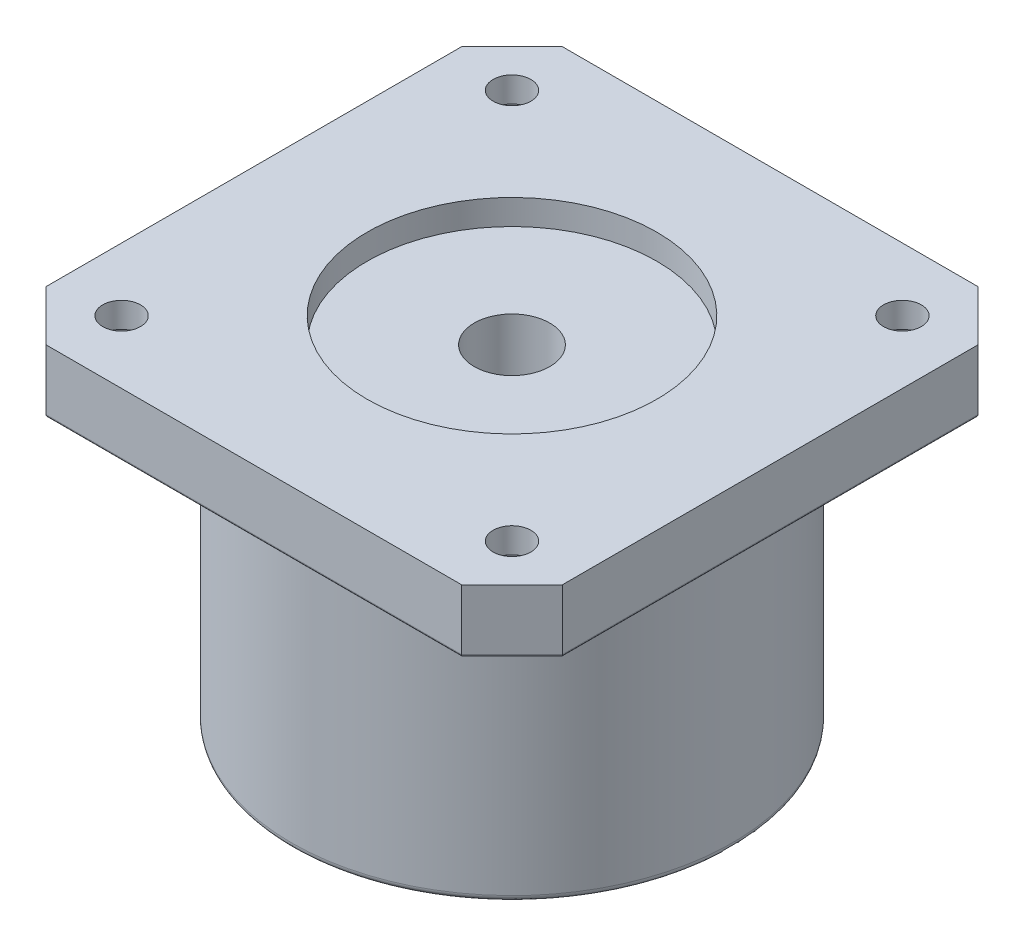
from build123d import *

# Parameters (mm, degrees)
SKETCH1_W           = 41
SKETCH1_H           = 41
BOSS_EXTRUDE1_DEPTH = 5
CUT_EXTRUDE2_DEPTH  = 5
SKETCH4_R           = 11.5
CUT_EXTRUDE3_DEPTH  = 2
SKETCH6_R           = 17.5
BOSS_EXTRUDE2_DEPTH = 23
FILLET1_R           = 0.2
FILLET2_R           = 0.5
SKETCH13_R          = 11
BOSS_EXTRUDE3_DEPTH = 2
SKETCH5_R           = 3
CUT_EXTRUDE9_DEPTH  = 31
SKETCH14_R          = 2.5
CUT_EXTRUDE10_DEPTH = 5
SKETCH15_R          = 1.5
CUT_EXTRUDE11_DEPTH = 5
SKETCH16_R          = 2.5
CUT_EXTRUDE12_DEPTH = 3
SKETCH17_R          = 1.5
CUT_EXTRUDE13_DEPTH = 3
SKETCH18_R          = 1.5
CUT_EXTRUDE14_DEPTH = 5


with BuildPart() as part:
    # Sketch1 → Boss-Extrude1 (new body)
    with BuildSketch(Plane(origin=(0, 0, 0), x_dir=(1, 0, 0), z_dir=(0, 1, 0))):
        with Locations((20.5, 20.5)):
            Rectangle(SKETCH1_W, SKETCH1_H)
    extrude(amount=BOSS_EXTRUDE1_DEPTH)

    # Sketch2 → Cut-Extrude2 (cut)
    with BuildSketch(Plane(origin=(0, 5, 0), x_dir=(1, 0, 0), z_dir=(0, 1, 0))):
        Polygon((0, 4), (0, 0), (4, 0), align=None)
        Polygon((0, 41), (0, 37), (4, 41), align=None)
        Polygon((41, 41), (37, 41), (41, 37), align=None)
        Polygon((41, 4), (37, 0), (41, 0), align=None)
    extrude(amount=-CUT_EXTRUDE2_DEPTH, mode=Mode.SUBTRACT)

    # Sketch4 → Cut-Extrude3 (cut)
    with BuildSketch(Plane(origin=(0, 5, 0), x_dir=(1, 0, 0), z_dir=(0, 1, 0))):
        with Locations((20.5, 20.5)):
            Circle(SKETCH4_R)
    extrude(amount=-CUT_EXTRUDE3_DEPTH, mode=Mode.SUBTRACT)

    # Sketch6 → Boss-Extrude2 (add)
    with BuildSketch(Plane.XZ):
        with Locations((20.5, -20.5)):
            Circle(SKETCH6_R)
    extrude(amount=BOSS_EXTRUDE2_DEPTH)

    # Fillet1
    fillet1_edges = [part.edges().sort_by_distance(p)[0] for p in [
        (20.5, 0, 0),
        (2, 0, -2),
        (0, 0, -20.5),
        (2, 0, -39),
        (20.5, 0, -41),
        (39, 0, -39),
        (41, 0, -20.5),
        (39, 0, -2),
    ]]
    fillet(fillet1_edges, radius=FILLET1_R)

    # Fillet2
    fillet2_edges = [part.edges().sort_by_distance(p)[0] for p in [
        (3, -23, -20.5),
    ]]
    fillet(fillet2_edges, radius=FILLET2_R)

    # Sketch13 → Boss-Extrude3 (add)
    with BuildSketch(Plane(origin=(0, -23, 0), x_dir=(-1, 0, 0), z_dir=(0, -1, 0))):
        with Locations((-20.5, 20.5)):
            Circle(SKETCH13_R)
    extrude(amount=BOSS_EXTRUDE3_DEPTH)

    # Sketch5 → Cut-Extrude9 (cut, through all)
    with BuildSketch(Plane(origin=(0, 5, 0), x_dir=(1, 0, 0), z_dir=(0, 1, 0))):
        with Locations((20.5, 20.5)):
            Circle(SKETCH5_R)
    extrude(amount=-CUT_EXTRUDE9_DEPTH, mode=Mode.SUBTRACT)

    # Sketch14 → Cut-Extrude10 (cut)
    with BuildSketch(Plane(origin=(0, -23, 0), x_dir=(-1, 0, 0), z_dir=(0, -1, 0))):
        with Locations((-20.5, 6.5)):
            Circle(SKETCH14_R)
        with Locations((-34.5, 20.5)):
            Circle(SKETCH14_R)
        with Locations((-20.5, 34.5)):
            Circle(SKETCH14_R)
        with Locations((-6.5, 20.5)):
            Circle(SKETCH14_R)
    extrude(amount=-CUT_EXTRUDE10_DEPTH, mode=Mode.SUBTRACT)

    # Sketch15 → Cut-Extrude11 (cut)
    with BuildSketch(Plane(origin=(0, -23, 0), x_dir=(-1, 0, 0), z_dir=(0, -1, 0))):
        with Locations((-6.357864376, 20.5)):
            Circle(SKETCH15_R)
        with Locations((-30.5, 10.5)):
            Circle(SKETCH15_R)
        with Locations((-20.5, 6.357864376)):
            Circle(SKETCH15_R)
        with Locations((-30.5, 30.5)):
            Circle(SKETCH15_R)
        with Locations((-34.642135624, 20.5)):
            Circle(SKETCH15_R)
        with Locations((-10.5, 30.5)):
            Circle(SKETCH15_R)
        with Locations((-20.5, 34.642135624)):
            Circle(SKETCH15_R)
        with Locations((-10.5, 10.5)):
            Circle(SKETCH15_R)
    extrude(amount=-CUT_EXTRUDE11_DEPTH, mode=Mode.SUBTRACT)

    # Sketch16 → Cut-Extrude12 (cut)
    with BuildSketch(Plane(origin=(0, 0, 0), x_dir=(-1, 0, 0), z_dir=(0, -1, 0))):
        with Locations((-5, 5)):
            Circle(SKETCH16_R)
        with Locations((-36, 5)):
            Circle(SKETCH16_R)
        with Locations((-5, 36)):
            Circle(SKETCH16_R)
        with Locations((-36, 36)):
            Circle(SKETCH16_R)
    extrude(amount=-CUT_EXTRUDE12_DEPTH, mode=Mode.SUBTRACT)

    # Sketch17 → Cut-Extrude13 (cut, through all)
    with BuildSketch(Plane(origin=(0, 3, 0), x_dir=(-1, 0, 0), z_dir=(0, -1, 0))):
        with Locations((-5, 5)):
            Circle(SKETCH17_R)
        with Locations((-36, 5)):
            Circle(SKETCH17_R)
        with Locations((-5, 36)):
            Circle(SKETCH17_R)
        with Locations((-36, 36)):
            Circle(SKETCH17_R)
    extrude(amount=-CUT_EXTRUDE13_DEPTH, mode=Mode.SUBTRACT)

    # Sketch18 → Cut-Extrude14 (cut)
    with BuildSketch(Plane.XZ.offset(18)):
        with Locations((6.5, -20.5)):
            Circle(SKETCH18_R)
        with Locations((34.5, -20.5)):
            Circle(SKETCH18_R)
        with Locations((20.5, -6.5)):
            Circle(SKETCH18_R)
        with Locations((20.5, -34.5)):
            Circle(SKETCH18_R)
    extrude(amount=-CUT_EXTRUDE14_DEPTH, mode=Mode.SUBTRACT)


solid = part.part
